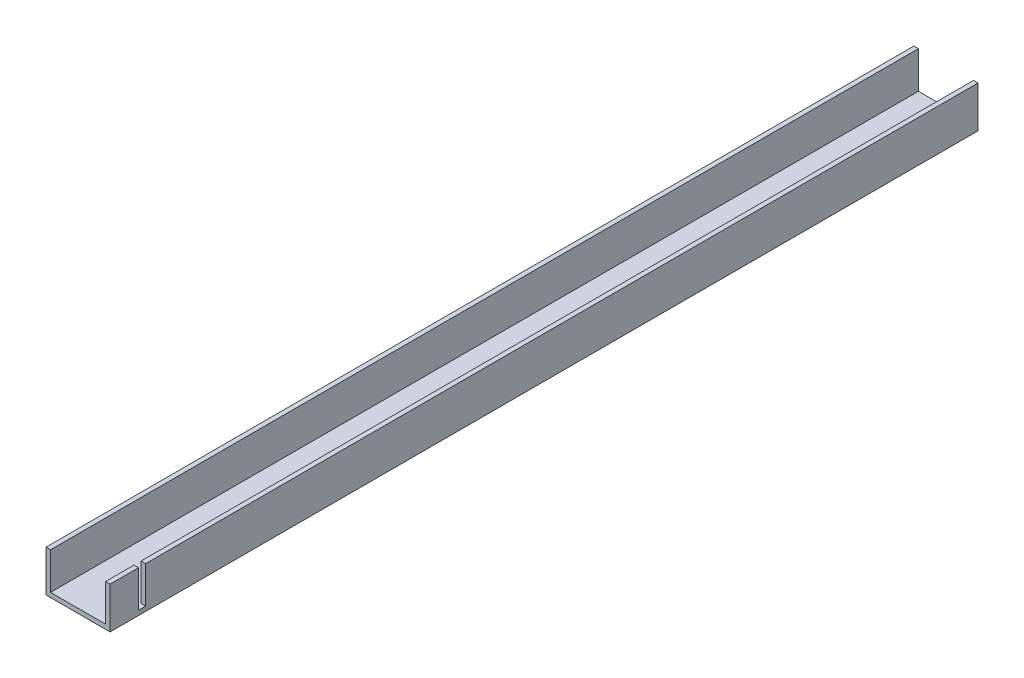
from build123d import *

# Parameters (mm, degrees)
BOSS_EXTRUDE1_DEPTH = 304.8
SKETCH3_W           = 2.5
SKETCH3_H           = 12.9625
CUT_EXTRUDE1_DEPTH  = 2.5875
SKETCH4_W           = 2.5
SKETCH4_H           = 50
CUT_EXTRUDE2_DEPTH  = 2.5875


with BuildPart() as part:
    # Sketch1 → Boss-Extrude1 (new body)
    with BuildSketch(Plane.XY):
        Polygon((0, 0), (0, 14.55), (1.5875, 14.55), (1.5875, 1.5875), (20.9125, 1.5875), (20.9125, 14.55), (22.5, 14.55), (22.5, 0), align=None)
    extrude(amount=BOSS_EXTRUDE1_DEPTH)

    # Sketch3 → Cut-Extrude1 (cut, through all)
    with BuildSketch(Plane.ZY.offset(-20.9125)):
        with Locations((293.55, 8.06875)):
            Rectangle(SKETCH3_W, SKETCH3_H)
    extrude(amount=-CUT_EXTRUDE1_DEPTH, mode=Mode.SUBTRACT)

    # Sketch4 → Cut-Extrude2 (cut, through all)
    with BuildSketch(Plane(origin=(0, 1.5875, 0), x_dir=(1, 0, 0), z_dir=(0, 1, 0))):
        with Locations((11.25, -25)):
            Rectangle(SKETCH4_W, SKETCH4_H)
    extrude(amount=-CUT_EXTRUDE2_DEPTH, mode=Mode.SUBTRACT)


solid = part.part
